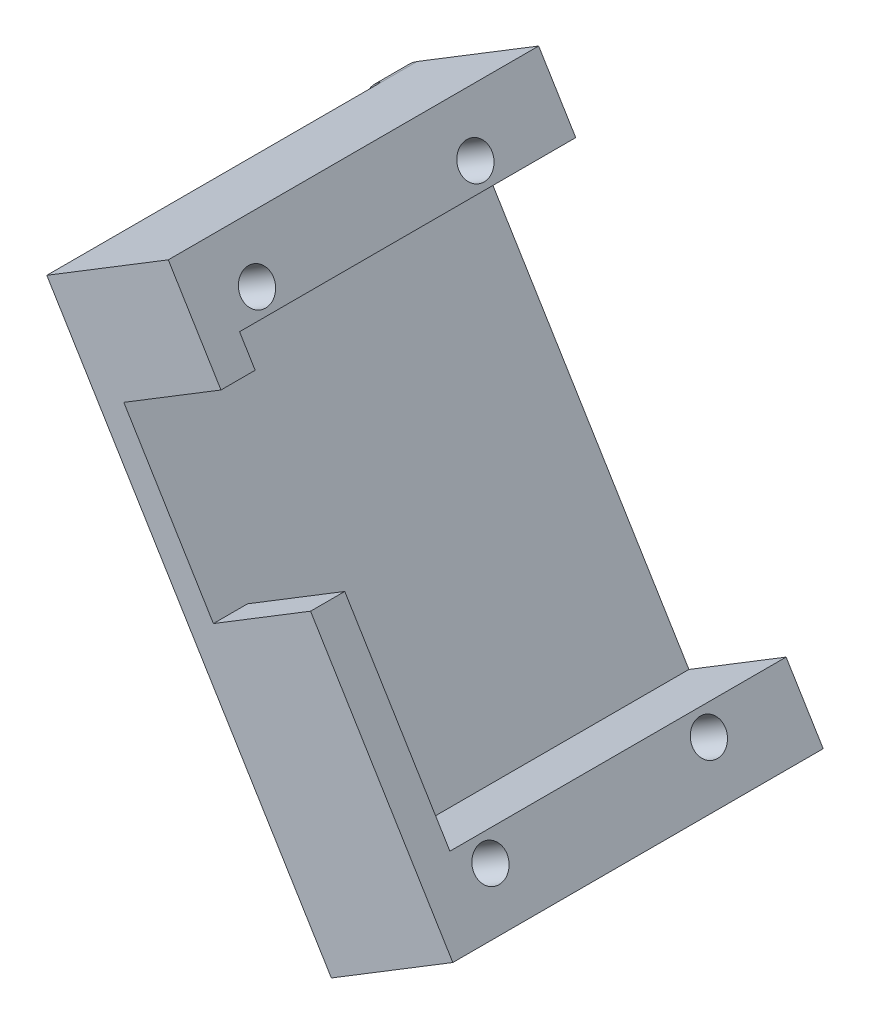
from build123d import *

# Parameters (mm, degrees)
BOSS_EXTRUDE1_DEPTH                               = 3.048
BOSS_EXTRUDE2_DEPTH                               = 29.971999999999998
BOSS_EXTRUDE3_DEPTH                               = 3.048
BOSS_EXTRUDE4_DEPTH                               = 3.048
SKETCH13_W                                        = 29.972
SKETCH13_H                                        = 48.7
BOSS_EXTRUDE5_DEPTH                               = 3.048
CSK_FOR_4_FLAT_HEAD_MACHINE_SCREW_100_D           = 2.9464
CSK_FOR_4_FLAT_HEAD_MACHINE_SCREW_100_CSINK_D     = 5.715
CSK_FOR_4_FLAT_HEAD_MACHINE_SCREW_100_CSINK_ANGLE = 100
CUT_EXTRUDE1_DEPTH                                = 1.397
CUT_EXTRUDE1_DEPTH_BACK                           = 1.397
SKETCH15_R                                        = 9.184035329670005
SKETCH15_R_2                                      = 8.124741076595411
SKETCH15_R_3                                      = 8.201451240556812
SKETCH15_R_4                                      = 5.810172256980604
BOSS_EXTRUDE6_DEPTH                               = 3.048
CSK_FOR_4_FLAT_HEAD_MACHINE_SCREW1_AT_2_COUNT     = 2
CSK_FOR_4_FLAT_HEAD_MACHINE_SCREW1_AT_2_PITCH     = 35.474094707842795
CSK_FOR_4_FLAT_HEAD_MACHINE_SCREW1_AT_3_COUNT     = 2
CSK_FOR_4_FLAT_HEAD_MACHINE_SCREW1_AT_3_PITCH     = 43.70753982500484
CSK_FOR_4_FLAT_HEAD_MACHINE_SCREW1_AT_4_COUNT     = 2
CSK_FOR_4_FLAT_HEAD_MACHINE_SCREW1_AT_4_PITCH     = 25.069264350610375
CUT_EXTRUDE2_DEPTH                                = 3.048
FILLET3_R                                         = 3.8099999999999996
FILLET4_R                                         = 1.27
SKETCH21_W                                        = 2.540000000000001
SKETCH21_H                                        = 33.02
CUT_EXTRUDE3_DEPTH                                = 77.47
FILLET5_R                                         = 0.508
FILLET6_R                                         = 0.508
SKETCH22_W                                        = 123.04970813102194
SKETCH22_H                                        = 134.7131875745612
CUT_EXTRUDE4_DEPTH                                = 61.72200000000001


with BuildPart() as part:
    # Sketch2 → Boss-Extrude1 (new body)
    with BuildSketch(Plane.XY):
        Polygon((-47.58059551455695, 48.12489153745831), (-22.21147896413696, 6.554494312375088), (5.701292889255674, 23.58878817682547), (-19.667823661164306, 65.1591854019087), align=None)
        Polygon((-38.85234269167306, 46.0124042215628), (-20.098991648241444, 15.282747135258976), (-3.0269599336282123, 25.701275492720985), (-21.78031097705982, 56.430932579024805), align=None, mode=Mode.SUBTRACT)
    extrude(amount=BOSS_EXTRUDE1_DEPTH)

    # Sketch3 → Boss-Extrude2 (add)
    with BuildSketch(Plane.XY.offset(3.048)):
        Polygon((2.4490708476218597, 21.604058524728963), (-22.920045702798127, 63.17445574981219), (-44.328373472923126, 50.10962118955482), (-18.95925692250314, 8.539223964471608), align=None)
        Polygon((-38.85234269167306, 46.0124042215628), (-20.098991648241444, 15.282747135258976), (-3.0269599336282087, 25.701275492720985), (-21.78031097705982, 56.430932579024805), align=None, mode=Mode.SUBTRACT)
    extrude(amount=BOSS_EXTRUDE2_DEPTH)

    # Sketch4 → Boss-Extrude3 (add)
    with BuildSketch(Plane.XY.offset(33.02)):
        Polygon((-38.85234269167306, 46.0124042215628), (-37.46131723814535, 43.733039051773666), (-20.389285523532113, 54.15156740923567), (-21.78031097705982, 56.430932579024805), align=None)
        Polygon((-29.47566716995725, 30.647575678410885), (-12.403635455344016, 41.0661040358729), (-3.0269599336282087, 25.701275492720985), (-20.098991648241444, 15.282747135258976), align=None)
    extrude(amount=-BOSS_EXTRUDE3_DEPTH)

    # Sketch12 → Boss-Extrude4 (add)
    with BuildSketch(Plane.XY.offset(3.048)):
        Polygon((2.4490708476218597, 21.604058524728963), (5.701292889255674, 23.58878817682547), (8.120429940678708, 25.065112049236276), (-17.248686609741274, 66.6355092743195), (-22.920045702798127, 63.17445574981219), align=None)
    extrude(amount=-BOSS_EXTRUDE4_DEPTH)

    # Sketch13 → Boss-Extrude5 (add)
    with BuildSketch(Plane(origin=(11.391019162328917, 6.95158362794815, 0), x_dir=(0, 0, -1), z_dir=(0.8536015857306615, 0.5209264178731006, 0))):
        with Locations((-18.034000000000002, 41.515472911157566)):
            Rectangle(SKETCH13_W, SKETCH13_H)
    extrude(amount=BOSS_EXTRUDE5_DEPTH)

    # CSK for #4 Flat Head Machine Screw (100)2 (through all)
    with Locations(Plane(origin=(-10.017308607796087, -6.113250932309213, 0), x_dir=(0, 0, 1), z_dir=(-0.8536015857306615, -0.5209264178731007, 0))):
        with Locations((27.397617355, 61.471448289), (7.925915452, 61.471448289), (7.925915452, 21.515515982), (27.397617355, 21.515515982)):
            CounterSinkHole(CSK_FOR_4_FLAT_HEAD_MACHINE_SCREW_100_D / 2, CSK_FOR_4_FLAT_HEAD_MACHINE_SCREW_100_CSINK_D / 2, counter_sink_angle=CSK_FOR_4_FLAT_HEAD_MACHINE_SCREW_100_CSINK_ANGLE)

    # Sketch14 → Cut-Extrude1 (cut, two sides: drawn at the far end of the back side and taken through both)
    with BuildSketch(Plane(origin=(11.607833965104508, 7.083898938087922, 0), x_dir=(0, 0, -1), z_dir=(0.8536015857306615, 0.5209264178731005, 0)).offset(-CUT_EXTRUDE1_DEPTH_BACK)):
        Polygon((-30.697174143874744, 19.61051598216394), (-30.697174143874744, 14.979833054183299), (-24.09806056703731, 14.979833054183299), (-24.09806056703731, 19.610515982163985), (-24.098060567037347, 23.42051598216399), (-27.39761735545604, 25.325515982163957), (-30.697174143874758, 23.420515982163952), align=None)
        Polygon((-27.39761735545604, 57.661448288693826), (-24.098060567037333, 59.56644828869383), (-24.098060567037336, 63.37644828869381), (-24.098060567037336, 70.99644828869384), (-30.69717414387474, 70.99644828869384), (-30.69717414387474, 63.37644828869381), (-30.69717414387474, 59.56644828869381), align=None)
        Polygon((-7.925915451689084, 57.661448288693826), (-4.626358663270381, 59.56644828869382), (-4.626358663270402, 63.37644828869381), (-4.626358663270402, 70.99644828869384), (-11.225472240107786, 70.99644828869384), (-11.225472240107786, 63.376448288693766), (-11.225472240107747, 59.566448288693785), align=None)
        Polygon((-7.925915451689081, 25.325515982163946), (-11.225472240107791, 23.42051598216395), (-11.225472240107791, 19.610515982163946), (-11.225472240107791, 14.979833054183299), (-4.626358663270366, 14.979833054183299), (-4.626358663270366, 19.610515982163953), (-4.6263586632703655, 23.420515982163952), align=None)
    extrude(amount=CUT_EXTRUDE1_DEPTH + CUT_EXTRUDE1_DEPTH_BACK, mode=Mode.SUBTRACT)

    # Sketch15 → Boss-Extrude6 (add)
    with BuildSketch(Plane(origin=(0, 0, 0), x_dir=(-1, 0, 0), z_dir=(0, 0, -1))):
        with Locations((9.758086495919196, 54.36124573948299)):
            Circle(SKETCH15_R)
        with Locations((39.927818301519274, 35.58488100974543)):
            Circle(SKETCH15_R_2)
        with Locations((25.610425726235285, 18.04643091882164)):
            Circle(SKETCH15_R_3)
        with Locations((-3.4576236647063787, 32.70568986323082)):
            Circle(SKETCH15_R_4)
    extrude(amount=-BOSS_EXTRUDE6_DEPTH)

    # Sketch19 → CSK for #4 Flat Head Machine Screw1 (revolve, cut)
    with BuildSketch(Plane(origin=(3.764373982237945, 32.86032278852424, 3.048), x_dir=(0, -1, 0), z_dir=(1, 0, 0))):
        Polygon((0, 0), (-7.5e-16, 3.0480000000000023), (1.4731999999999932, 3.0480000000000023), (1.4731999999999934, 1.59245498611605), (2.857499999999999, -1.73e-15), align=None)
    csk_for_4_flat_head_machine_screw1 = revolve(axis=Axis((3.764373982237945, 32.86032278852424, 9.39799999999999), (0, 0, -1)), mode=Mode.SUBTRACT)

    # CSK for #4 Flat Head Machine Screw1 at 2: CSK for #4 Flat Head Machine Screw1 ×2
    with Locations(*[Vector(-0.8506492202713736, -0.5257336816789507, 0) * (i * CSK_FOR_4_FLAT_HEAD_MACHINE_SCREW1_AT_2_PITCH) for i in range(1, CSK_FOR_4_FLAT_HEAD_MACHINE_SCREW1_AT_2_COUNT)]):
        add(csk_for_4_flat_head_machine_screw1, mode=Mode.SUBTRACT)

    # CSK for #4 Flat Head Machine Screw1 at 3: CSK for #4 Flat Head Machine Screw1 ×2
    with Locations(*[Vector(-0.997755305773639, 0.06696528802709796, 0) * (i * CSK_FOR_4_FLAT_HEAD_MACHINE_SCREW1_AT_3_PITCH) for i in range(1, CSK_FOR_4_FLAT_HEAD_MACHINE_SCREW1_AT_3_COUNT)]):
        add(csk_for_4_flat_head_machine_screw1, mode=Mode.SUBTRACT)

    # CSK for #4 Flat Head Machine Screw1 at 4: CSK for #4 Flat Head Machine Screw1 ×2
    with Locations(*[Vector(-0.5210117203175807, 0.8535495224600124, 0) * (i * CSK_FOR_4_FLAT_HEAD_MACHINE_SCREW1_AT_4_PITCH) for i in range(1, CSK_FOR_4_FLAT_HEAD_MACHINE_SCREW1_AT_4_COUNT)]):
        add(csk_for_4_flat_head_machine_screw1, mode=Mode.SUBTRACT)

    # Sketch20 → Cut-Extrude2 (cut)
    with BuildSketch(Plane(origin=(0, 0, 0), x_dir=(-1, 0, 0), z_dir=(0, 0, -1))):
        with BuildLine():
            Line((14.542293121824187, 62.20075286029573), (11.563953125478477, 57.32037886408755))
            ThreePointArc((11.563953125478477, 57.32037886408755), (6.044784522535942, 56.24291105550805), (7.610320649443919, 50.84186897257834))
            Line((7.610320649443919, 50.84186897257834), (-1.4954062126549716, 35.92102291440944))
            ThreePointArc((-1.4954062126549716, 35.92102291440944), (-7.016596023871767, 34.845052440620755), (-5.448804035753348, 29.442897530407524))
            Line((-5.448804035753348, 29.442897530407524), (-6.484295885760952, 27.746117611303884))
            Line((-6.484295885760952, 27.746117611303884), (-6.762670750549963, 27.28996638176623))
            Line((-6.762670750549963, 27.28996638176623), (-14.061950278269341, 31.74448896114331))
            Line((-14.061950278269341, 31.74448896114331), (8.559037851416688, 68.81174198534737))
            Line((8.559037851416688, 68.81174198534737), (14.542293121824187, 65.16034795406075))
            Line((14.542293121824187, 65.16034795406075), (14.542293121824187, 62.20075286029573))
        make_face()
        Polygon((21.78031097705982, 56.430932579024805), (38.85234269167306, 46.0124042215628), (20.098991648241444, 15.282747135258976), (3.0269599336282123, 25.701275492720985), align=None)
        with BuildLine():
            Line((22.21147896413696, 6.554494312375088), (24.781951964671258, 10.766528400207497))
            ThreePointArc((24.781951964671258, 10.766528400207497), (29.66385906245521, 12.225666721445755), (28.72915433514684, 17.23450177808784))
            Line((28.72915433514684, 17.23450177808784), (38.012718373529104, 32.44675577885475))
            ThreePointArc((38.012718373529104, 32.44675577885475), (43.097277822107074, 33.802481129765034), (41.97793801322115, 38.944252653808825))
            Line((41.97793801322115, 38.944252653808825), (47.58059551455695, 48.12489153745831))
            Line((47.58059551455695, 48.12489153745831), (51.80171473929435, 35.787210781861546))
            Line((51.80171473929435, 35.787210781861546), (47.57680035710003, 5.227667032097241))
            Line((47.57680035710003, 5.227667032097241), (22.21147896413696, 6.554494312375088))
        make_face()
    extrude(amount=-CUT_EXTRUDE2_DEPTH, mode=Mode.SUBTRACT)


with BuildPart() as body_2:
    # of the pieces the cut leaves, the one that is kept (cut_extrude2_keep)
    add(part.part.solids().sort_by_distance((-47.580595515, 48.124891537, 0))[0])

    # Fillet3
    fillet3_edges = [body_2.edges().sort_by_distance(p)[0] for p in [
        (-17.248686609741274, 66.6355092743195, 1.524),
        (-47.58059551455695, 48.12489153745831, 1.524),
        (-22.21147896413696, 6.554494312375088, 1.524),
        (8.120429940678708, 25.065112049236276, 1.524),
    ]]
    fillet(fillet3_edges, radius=FILLET3_R)

    # Fillet4
    fillet4_edges = [body_2.edges().sort_by_distance(p)[0] for p in [
        (1.4954062126549714, 35.92102291440944, 1.524),
        (-24.781951964671258, 10.766528400207495, 1.524),
        (-28.72915433514684, 17.23450177808784, 1.524),
        (-38.0127183735291, 32.44675577885475, 1.524),
        (-41.97793801322115, 38.94425265380882, 1.524),
        (-11.563953125478475, 57.320378864087544, 1.524),
        (-7.610320649443917, 50.84186897257834, 1.524),
    ]]
    fillet(fillet4_edges, radius=FILLET4_R)

    # Sketch21 → Cut-Extrude3 (cut)
    with BuildSketch(Plane(origin=(-8.941948314707059, 14.652474896780824, 0), x_dir=(0.8536015857306616, 0.5209264178731006, 0), z_dir=(0.5209264178731005, -0.8536015857306615, 0))):
        with Locations((2.2216732427396275, 16.51)):
            Rectangle(SKETCH21_W, SKETCH21_H)
    extrude(amount=-CUT_EXTRUDE3_DEPTH, mode=Mode.SUBTRACT)


with BuildPart() as cut_extrude3_piece_1:
    # of the separate pieces the step leaves, piece 1, a body of its own (cut_extrude3_pieces)
    add(body_2.part.solids().sort_by_distance((-12.188709065, 58.344117807, 0))[0])

    # Fillet6
    fillet6_edges = [cut_extrude3_piece_1.edges().sort_by_distance(p)[0] for p in [
        (-7.633709794281099, 43.97704085894782, 3.048),
    ]]
    fillet(fillet6_edges, radius=FILLET6_R)

    # Sketch22 → Cut-Extrude4 (cut)
    with BuildSketch(Plane(origin=(2.067982642978631, 1.2620252919381492, 0), x_dir=(0, 0, -1), z_dir=(0.8536015857306616, 0.5209264178731006, 0))):
        with Locations((-42.687564536567926, 74.45417523171726)):
            Rectangle(SKETCH22_W, SKETCH22_H)
    extrude(amount=CUT_EXTRUDE4_DEPTH, mode=Mode.SUBTRACT)


with BuildPart() as cut_extrude3_piece_2:
    # of the separate pieces the step leaves, piece 2, a body of its own (cut_extrude3_pieces)
    add(body_2.part.solids().sort_by_distance((-42.532157132, 39.852408399, 0))[0])

    # Fillet5
    fillet5_edges = [cut_extrude3_piece_2.edges().sort_by_distance(p)[0] for p in [
        (-31.64381519771313, 29.324422577013216, 3.048),
    ]]
    fillet(fillet5_edges, radius=FILLET5_R)


solid = cut_extrude3_piece_2.part
